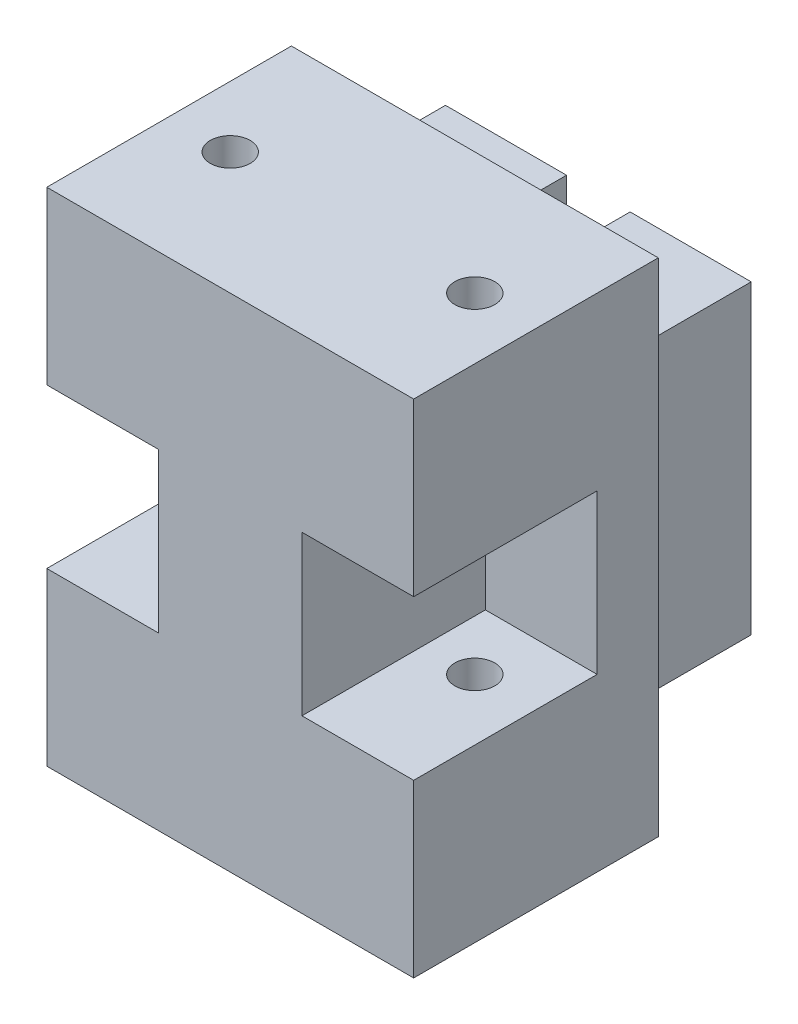
from build123d import *

# Parameters (mm, degrees)
BOSS_EXTRUDE1_DEPTH     = 20
SKETCH3_R               = 1.632108338
CUT_EXTRUDE1_DEPTH      = 33.330326321
CUT_EXTRUDE1_DEPTH_BACK = 33.330326321
SKETCH4_W               = 30
SKETCH4_H               = 41
BOSS_EXTRUDE2_DEPTH     = 5
SKETCH6_W               = 25
SKETCH6_H               = 25
BOSS_EXTRUDE3_DEPTH     = 20
CUT_EXTRUDE4_START      = 12.5
CUT_EXTRUDE4_DEPTH      = 20
SKETCH8_W               = 9.9
SKETCH8_H               = 9.9
SKETCH8_W_2             = 15.1
CUT_EXTRUDE5_DEPTH      = 33.330326321
CUT_EXTRUDE5_DEPTH_BACK = 33.330326321


with BuildPart() as part:
    # Sketch2 → Boss-Extrude1 (new body)
    with BuildSketch(Plane.XY):
        Polygon((0, 20.5), (-15, 20.5), (-15, 6.5), (-5.864885696, 6.5), (-5.864885696, -6.5), (-15, -6.5), (-15, -20.5), (0, -20.5), (15, -20.5), (15, -6.5), (5.864885696, -6.5), (5.864885696, 6.5), (15, 6.5), (15, 20.5), align=None)
    extrude(amount=BOSS_EXTRUDE1_DEPTH)

    # Sketch3 → Cut-Extrude1 (cut, two sides)
    with BuildSketch(Plane(origin=(0, 0, 0), x_dir=(1, 0, 0), z_dir=(0, 1, 0))) as cut_extrude1_sk:
        with Locations(Location((-10, -10, 0), (0, 0, 270))):
            Circle(SKETCH3_R)
        with Locations(Location((10, -10, 0), (0, 0, 270))):
            Circle(SKETCH3_R)
    extrude(amount=CUT_EXTRUDE1_DEPTH, mode=Mode.SUBTRACT)
    extrude(cut_extrude1_sk.sketch, amount=-CUT_EXTRUDE1_DEPTH_BACK, mode=Mode.SUBTRACT)

    # Sketch4 → Boss-Extrude2 (add)
    with BuildSketch(Plane.XY):
        Rectangle(SKETCH4_W, SKETCH4_H)
    extrude(amount=BOSS_EXTRUDE2_DEPTH)

    # Sketch6 → Boss-Extrude3 (add)
    with BuildSketch(Plane.XY):
        Rectangle(SKETCH6_W, SKETCH6_H)
    extrude(amount=-BOSS_EXTRUDE3_DEPTH)

    # Sketch7 → Cut-Extrude4 (cut)
    with BuildSketch(Plane(origin=(0, 0, 0), x_dir=(1, 0, 0), z_dir=(0, 1, 0)).offset(CUT_EXTRUDE4_START)):
        Polygon((-2.6, 5.15), (-7.55, 5.15), (-7.55, 0), (0, 0), (0, 10.1), (-2.6, 10.1), align=None)
        Polygon((0, 10.1), (0, 0), (7.55, 0), (7.55, 5.15), (2.6, 5.15), (2.6, 10.1), align=None)
    extrude(amount=-CUT_EXTRUDE4_DEPTH, mode=Mode.SUBTRACT)

    # Sketch8 → Cut-Extrude5 (cut, two sides)
    with BuildSketch(Plane(origin=(0, 0, 0), x_dir=(1, 0, 0), z_dir=(0, 1, 0))) as cut_extrude5_sk:
        with Locations((-7.55, 15.05)):
            Rectangle(SKETCH8_W, SKETCH8_H)
        with Locations((4.95, 15.05)):
            Rectangle(SKETCH8_W_2, SKETCH8_H)
    extrude(amount=CUT_EXTRUDE5_DEPTH, mode=Mode.SUBTRACT)
    extrude(cut_extrude5_sk.sketch, amount=-CUT_EXTRUDE5_DEPTH_BACK, mode=Mode.SUBTRACT)


solid = part.part
